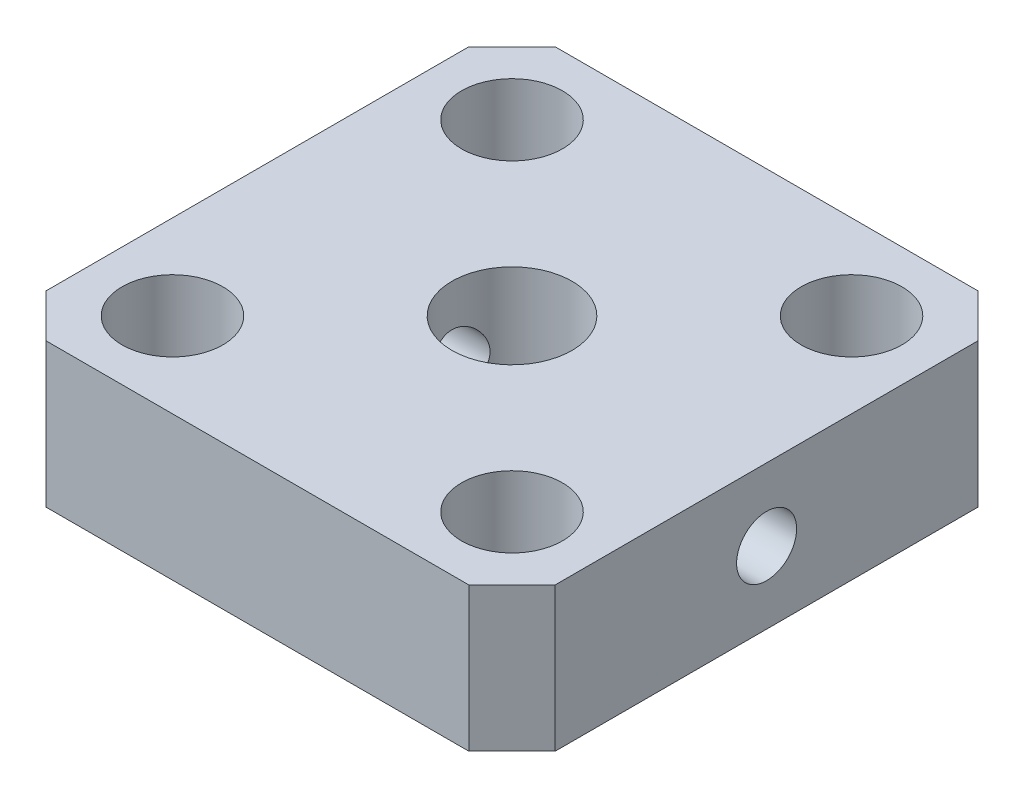
from build123d import *

# Parameters (mm, degrees)
SKETCH1_W             = 21.21
SKETCH1_H             = 21.21
SKETCH1_R             = 2.5
BOSS_EXTRUDE1_DEPTH   = 6
M5X0_8_TAPPED_HOLE1_D = 4.2
M3X0_5_TAPPED_HOLE1_D = 2.5
CHAMFER1_SIZE         = 1.8


with BuildPart() as part:
    # Sketch1 → Boss-Extrude1 (new body)
    with BuildSketch(Plane(origin=(0, 0, 0), x_dir=(1, 0, 0), z_dir=(0, 1, 0))):
        Rectangle(SKETCH1_W, SKETCH1_H)
        Circle(SKETCH1_R, mode=Mode.SUBTRACT)
    extrude(amount=BOSS_EXTRUDE1_DEPTH)

    # M5x0.8 Tapped Hole1 (through all)
    with Locations(Plane(origin=(0, 6, 0), x_dir=(1, 0, 0), z_dir=(0, 1, 0))):
        with Locations((-7.071067812, 7.071067812), (-7.071067812, -7.071067812), (7.071067812, -7.071067812), (7.071067812, 7.071067812)):
            Hole(M5X0_8_TAPPED_HOLE1_D / 2)

    # M3x0.5 Tapped Hole1 (through all)
    with Locations(Plane(origin=(10.605, 0, 0), x_dir=(0, 0, -1), z_dir=(1, 0, 0))):
        with Locations((0, 3)):
            Hole(M3X0_5_TAPPED_HOLE1_D / 2)

    # Chamfer1
    chamfer1_edges = [part.edges().sort_by_distance(p)[0] for p in [
        (-10.605, 3, -10.605),
        (10.605, 3, -10.605),
        (10.605, 3, 10.605),
        (-10.605, 3, 10.605),
    ]]
    chamfer(chamfer1_edges, length=CHAMFER1_SIZE)


solid = part.part
